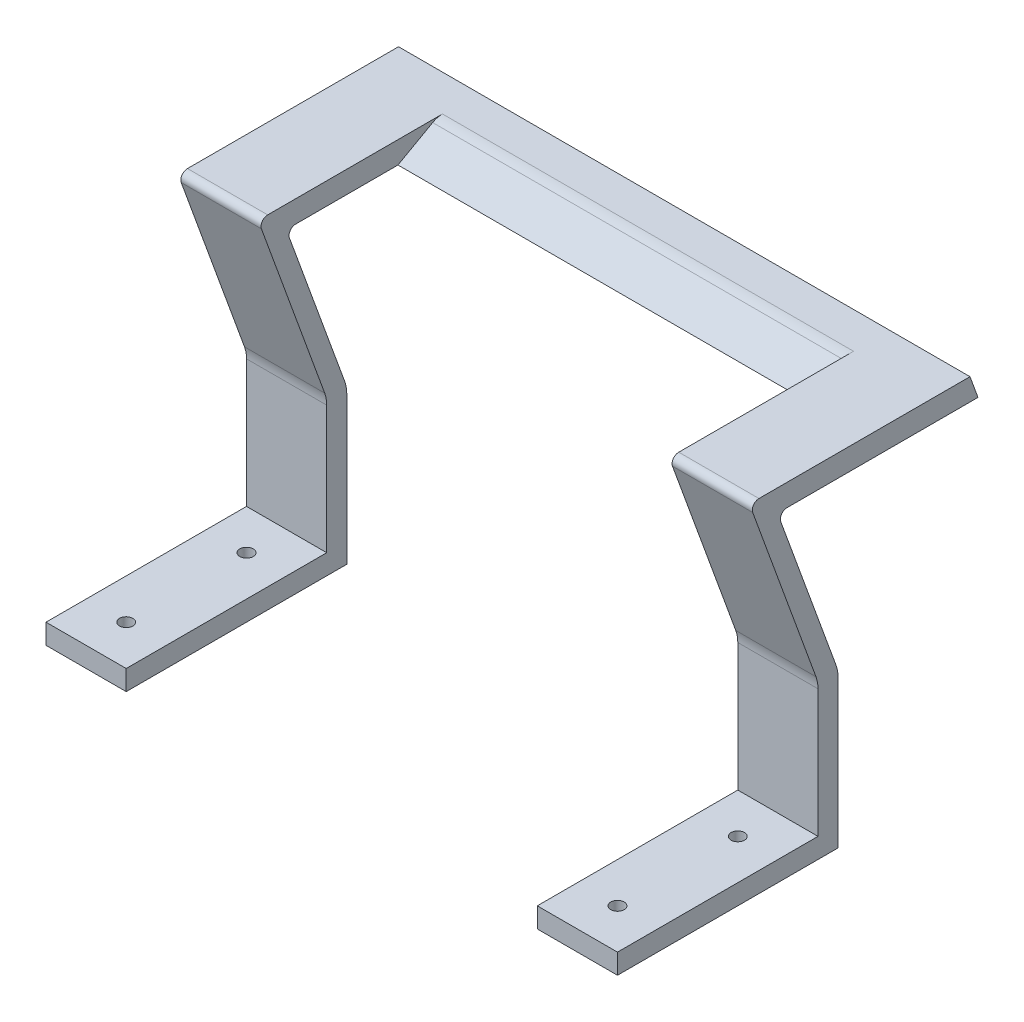
from build123d import *

# Parameters (mm, degrees)
SKETCH1_W             = 12
SKETCH1_H             = 33
SKETCH1_R             = 1
BOSS_EXTRUDE1_DEPTH   = 3
BOSS_EXTRUDE1_2_DEPTH = 3
SKETCH2_W             = 12
SKETCH2_H             = 3
BOSS_EXTRUDE2_DEPTH   = 20
SKETCH3_W             = 12
SKETCH3_H             = 3
BOSS_EXTRUDE3_DEPTH   = 30
SKETCH5_W             = 12
SKETCH5_H             = 3.5
BOSS_EXTRUDE4_DEPTH   = 30
BOSS_EXTRUDE5_DEPTH   = 61.5
FILLET2_R             = 1
FILLET3_R             = 3
FILLET4_R             = 5
FILLET5_R             = 5
FILLET6_R             = 1


with BuildPart() as part:
    # Sketch1 → Boss-Extrude1 (new body)
    with BuildSketch(Plane(origin=(0, 0, 0), x_dir=(1, 0, 0), z_dir=(0, 1, 0))):
        with Locations((6, 16.5)):
            Rectangle(SKETCH1_W, SKETCH1_H)
        with Locations((6, 24)):
            Circle(SKETCH1_R, mode=Mode.SUBTRACT)
        with Locations((6, 6)):
            Circle(SKETCH1_R, mode=Mode.SUBTRACT)
    extrude(amount=BOSS_EXTRUDE1_DEPTH)



with BuildPart() as body_2:
    # Sketch1 → Boss-Extrude1 2 (new body)
    with BuildSketch(Plane(origin=(0, 0, 0), x_dir=(1, 0, 0), z_dir=(0, 1, 0))):
        with Locations((79.5, 16.5)):
            Rectangle(SKETCH1_W, SKETCH1_H)
        with Locations((79.5, 24)):
            Circle(SKETCH1_R, mode=Mode.SUBTRACT)
        with Locations((79.5, 6)):
            Circle(SKETCH1_R, mode=Mode.SUBTRACT)
    extrude(amount=BOSS_EXTRUDE1_2_DEPTH)


with BuildPart() as part_1:
    add(part.part)

    add(body_2.part)  # Boss-Extrude2 merges body 2
    # Sketch2 → Boss-Extrude2 (add)
    with BuildSketch(Plane(origin=(0, 3, 0), x_dir=(1, 0, 0), z_dir=(0, 1, 0))):
        with Locations((6, 31.5)):
            Rectangle(SKETCH2_W, SKETCH2_H)
        with Locations((79.5, 31.5)):
            Rectangle(SKETCH2_W, SKETCH2_H)
    extrude(amount=BOSS_EXTRUDE2_DEPTH)

    # Sketch3 → Boss-Extrude3 (add, along a direction that is not the sketch's normal)
    with BuildSketch(Plane(origin=(0, 23, 0), x_dir=(1, 0, 0), z_dir=(0, 1, 0))):
        with Locations((79.5, 31.5)):
            Rectangle(SKETCH3_W, SKETCH3_H)
        with Locations((6, 31.5)):
            Rectangle(SKETCH3_W, SKETCH3_H)
    extrude(amount=BOSS_EXTRUDE3_DEPTH, dir=(0, 0.939692621, 0.342020143))

    # Sketch5 → Boss-Extrude4 (add, along a direction that is not the sketch's normal)
    with BuildSketch(Plane(origin=(0, 13.296484464, -36.531790823), x_dir=(-1, 0, 0), z_dir=(0, 0.342020143, -0.939692621))):
        with Locations((-79.5, 38.576265548)):
            Rectangle(SKETCH5_W, SKETCH5_H)
        with Locations((-6, 38.576265548)):
            Rectangle(SKETCH5_W, SKETCH5_H)
    extrude(amount=BOSS_EXTRUDE4_DEPTH, dir=(0, 0, -1))

    # Sketch6 → Boss-Extrude5 (add)
    with BuildSketch(Plane(origin=(12, 0, 0), x_dir=(0, 0, -1), z_dir=(1, 0, 0))):
        Polygon((53.936466202, 47.901854451), (52.7393957, 51.190778624), (46.533858727, 51.190778624), (40.660160277, 47.901854451), align=None)
    extrude(amount=BOSS_EXTRUDE5_DEPTH)

    # Fillet2
    fillet2_edges = [part_1.edges().sort_by_distance(p)[0] for p in [
        (6, 51.190778624, -19.7393957),
        (79.5, 51.190778624, -19.7393957),
    ]]
    fillet(fillet2_edges, radius=FILLET2_R)

    # Fillet3
    fillet3_edges = [part_1.edges().sort_by_distance(p)[0] for p in [
        (42.75, 51.190778624, -46.533858727),
    ]]
    fillet(fillet3_edges, radius=FILLET3_R)

    # Fillet4
    fillet4_edges = [part_1.edges().sort_by_distance(p)[0] for p in [
        (6, 23, -33),
        (79.5, 23, -33),
    ]]
    fillet(fillet4_edges, radius=FILLET4_R)

    # Fillet5
    fillet5_edges = [part_1.edges().sort_by_distance(p)[0] for p in [
        (6, 23, -30),
        (79.5, 23, -30),
    ]]
    fillet(fillet5_edges, radius=FILLET5_R)

    # Fillet6
    fillet6_edges = [part_1.edges().sort_by_distance(p)[0] for p in [
        (6, 47.901854451, -23.936466202),
        (79.5, 47.901854451, -23.936466202),
    ]]
    fillet(fillet6_edges, radius=FILLET6_R)


solid = part_1.part
